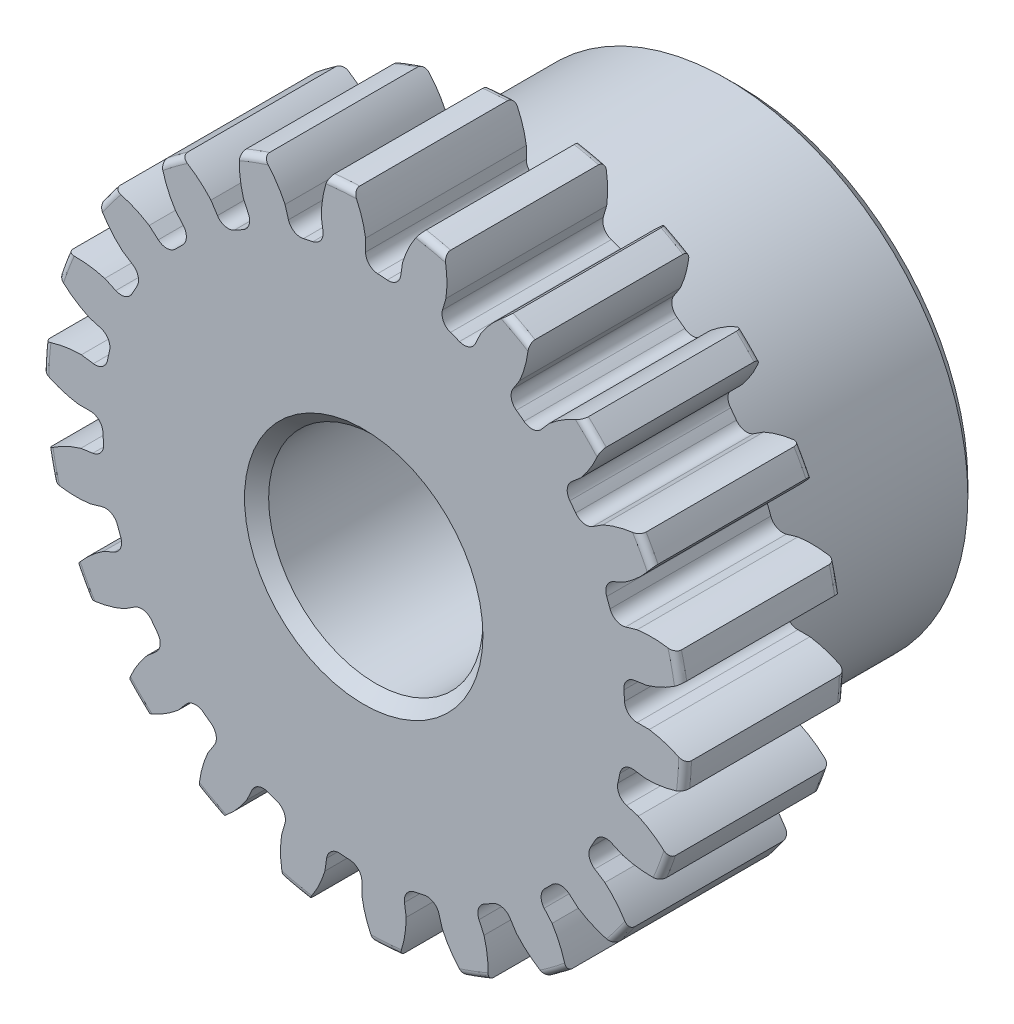
from build123d import *

# Parameters (mm, degrees)
SKETCH1_R                = 9.525
BOSS_EXTRUDE1_DEPTH      = 4.7625
SKETCH2_W                = 6.35
SKETCH2_H                = 7.14375
FILLET2_R                = 0.1905
CUT_EXTRUDE1_DEPTH       = 12.1125
FILLET1_R                = 0.374318784
CIRPATTERN1_COUNT        = 22
FILLET1_OF_CIRPATTERN1_R = 0.374318784
SKETCH5_R                = 3.175
CUT_EXTRUDE2_DEPTH       = 12.1125
CHAMFER1_SIZE            = 0.3571875


with BuildPart() as part:
    # Sketch1 → Boss-Extrude1 (new body)
    with BuildSketch(Plane.XY):
        Circle(SKETCH1_R)
    extrude(amount=-BOSS_EXTRUDE1_DEPTH)

    # Sketch2 → Revolve1 (revolve)
    with BuildSketch(Plane(origin=(0, 0, 0), x_dir=(0, 0, -1), z_dir=(1, 0, 0))):
        with Locations((7.9375, 3.571875)):
            Rectangle(SKETCH2_W, SKETCH2_H)
    revolve(axis=Axis((0, 0, -4.7625), (0, 0, -1)))

    # Fillet2
    fillet2_edges = [part.edges().sort_by_distance(p)[0] for p in [
        (-9.525, 0, 0),
        (-9.525, 0, -4.7625),
        (0, -7.14375, -4.7625),
    ]]
    fillet(fillet2_edges, radius=FILLET2_R)

    # Sketch4 → Cut-Extrude1 (cut, through all)
    with BuildSketch(Plane.XY):
        with BuildLine():
            Line((0.054821567, 8.459109181), (0.054821567, 7.73756943))
            ThreePointArc((0.054821567, 7.73756943), (0.552007026, 7.718048609), (1.04690994, 7.666613703))
            Line((1.04690994, 7.666613703), (1.149595991, 8.380809185))
            add(Edge.make_bspline(
                [(2.328590945, 10.036363463), (1.44460819, 9.360987761), (1.149595991, 8.380809185)],
                knots=[0, 0, 0, 1, 1, 1], degree=2))
            ThreePointArc((2.328590945, 10.036363463), (0.735006268, 10.276706337), (-0.876562375, 10.26560109))
            add(Edge.make_bspline(
                [(-0.876562375, 10.26560109), (-0.097693539, 9.471295617), (0.054821567, 8.459109181)],
                knots=[0, 0, 0, 1, 1, 1], degree=2))
        make_face()
    cut_extrude1 = extrude(amount=-CUT_EXTRUDE1_DEPTH, mode=Mode.SUBTRACT)

    # Fillet1
    fillet1_edges = [part.edges().sort_by_distance(p)[0] for p in [
        (1.04690994, 7.666613703, -2.38125),
        (0.054821567, 7.73756943, -2.38125),
    ]]
    fillet(fillet1_edges, radius=FILLET1_R)

    # CirPattern1: Cut-Extrude1 ×22 about axis
    cirpattern1_axis = Axis((0, 0, -4.7625), (0, 0, 1))
    for i in range(1, CIRPATTERN1_COUNT):
        add(cut_extrude1.rotate(cirpattern1_axis, i * 360 / CIRPATTERN1_COUNT), mode=Mode.SUBTRACT)

    # Fillet1 of CirPattern1
    fillet1_of_cirpattern1_edges = [part.edges().sort_by_distance(p)[0] for p in [
        (-1.15543195, 7.651010593, -2.38125),
        (-2.127324311, 7.439588521, -2.38125),
        (-3.264167614, 7.015568108, -2.38125),
        (-4.137127025, 6.538896396, -2.38125),
        (-5.108459831, 5.811766018, -2.38125),
        (-5.811764312, 5.108461772, -2.38125),
        (-6.538895014, 4.137129208, -2.38125),
        (-7.015567018, 3.264169957, -2.38125),
        (-7.439587811, 2.127326795, -2.38125),
        (-7.651010208, 1.155434505, -2.38125),
        (-7.737569449, -0.054818983, -2.38125),
        (-7.666614053, -1.04690738, -2.38125),
        (-7.408699226, -2.232523654, -2.38125),
        (-7.061114422, -3.164435054, -2.38125),
        (-6.479620254, -4.229362535, -2.38125),
        (-5.883565295, -5.02559902, -2.38125),
        (-5.025600985, -5.883563617, -2.38125),
        (-4.229364699, -6.479618842, -2.38125),
        (-3.164437412, -7.061113365, -2.38125),
        (-2.232526128, -7.408698481, -2.38125),
        (-1.04690994, -7.666613703, -2.38125),
        (-0.054821567, -7.73756943, -2.38125),
        (1.15543195, -7.651010593, -2.38125),
        (2.127324311, -7.439588521, -2.38125),
        (3.264167614, -7.015568108, -2.38125),
        (4.137127025, -6.538896396, -2.38125),
        (5.108459831, -5.811766018, -2.38125),
        (5.811764312, -5.108461772, -2.38125),
        (6.538895014, -4.137129208, -2.38125),
        (7.015567018, -3.264169957, -2.38125),
        (7.439587811, -2.127326795, -2.38125),
        (7.651010208, -1.155434505, -2.38125),
        (7.737569449, 0.054818983, -2.38125),
        (7.666614053, 1.04690738, -2.38125),
        (7.408699226, 2.232523654, -2.38125),
        (7.061114422, 3.164435054, -2.38125),
        (6.479620254, 4.229362535, -2.38125),
        (5.883565295, 5.02559902, -2.38125),
        (5.025600985, 5.883563617, -2.38125),
        (4.229364699, 6.479618842, -2.38125),
        (3.164437412, 7.061113365, -2.38125),
        (2.232526128, 7.408698481, -2.38125),
    ]]
    fillet(fillet1_of_cirpattern1_edges, radius=FILLET1_OF_CIRPATTERN1_R)

    # Sketch5 → Cut-Extrude2 (cut, through all)
    with BuildSketch(Plane.XY):
        Circle(SKETCH5_R)
    extrude(amount=-CUT_EXTRUDE2_DEPTH, mode=Mode.SUBTRACT)

    # Chamfer1
    chamfer1_edges = [part.edges().sort_by_distance(p)[0] for p in [
        (-3.175, 0, -11.1125),
        (-3.175, 0, 0),
        (0, -7.14375, -11.1125),
    ]]
    chamfer(chamfer1_edges, length=CHAMFER1_SIZE)


solid = part.part
